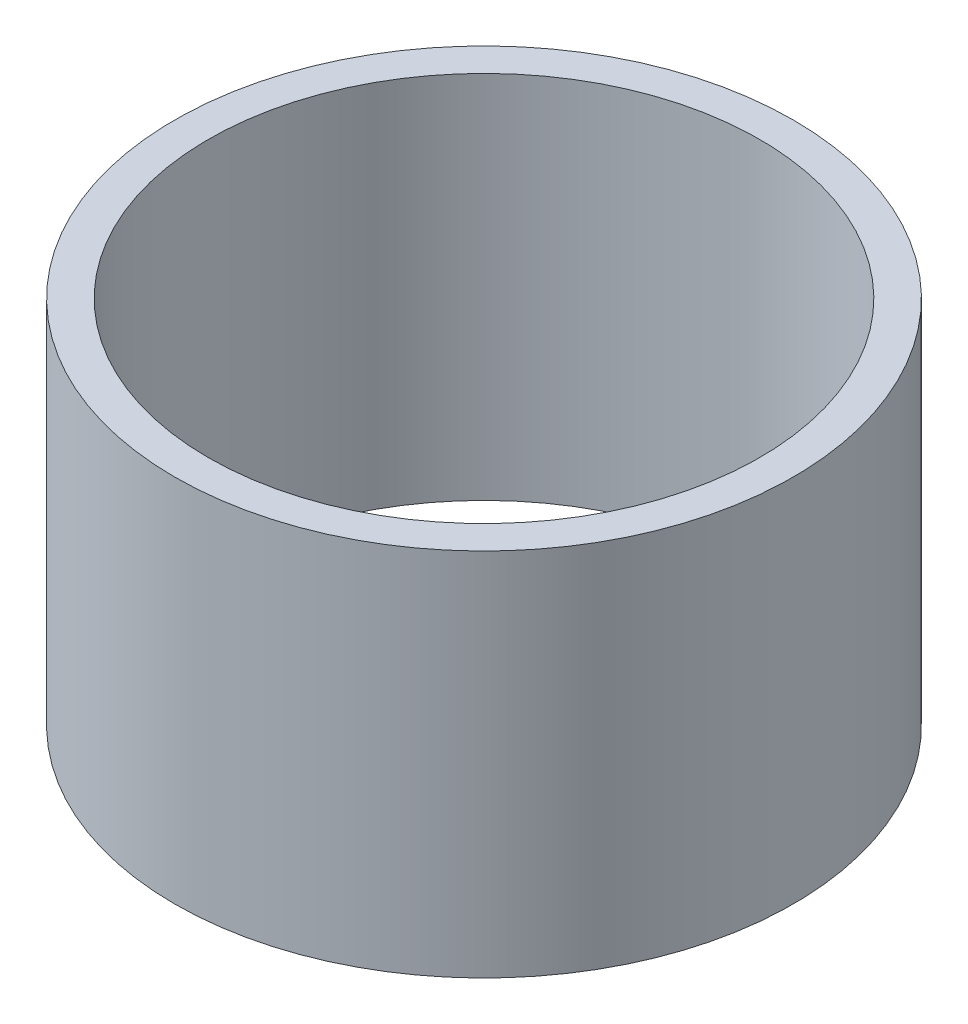
from build123d import *

# Parameters (mm, degrees)
SKETCH_1_R      = 23
SKETCH_1_R_2    = 20.5
EXTRUDE_1_DEPTH = 27.5


with BuildPart() as part:
    # 草图1 → 凸台-拉伸1 (new body)
    with BuildSketch(Plane(origin=(0, 0, 0), x_dir=(1, 0, 0), z_dir=(0, 1, 0))):
        Circle(SKETCH_1_R)
        Circle(SKETCH_1_R_2, mode=Mode.SUBTRACT)
    extrude(amount=EXTRUDE_1_DEPTH)


solid = part.part
